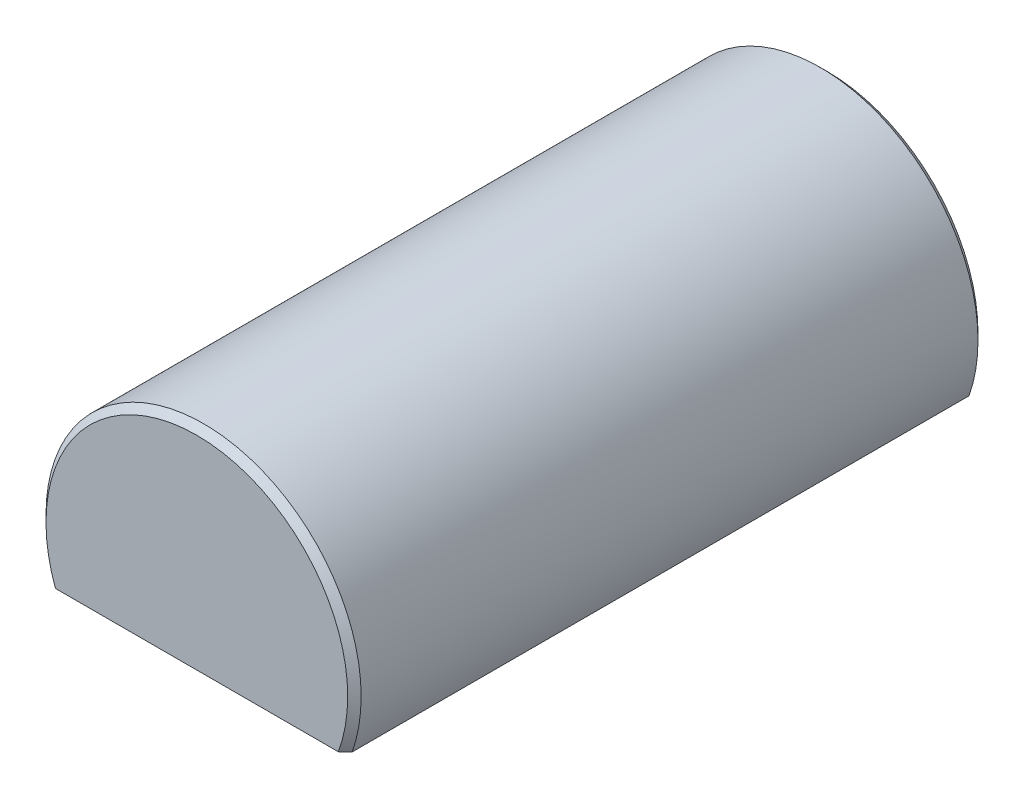
from build123d import *

# Parameters (mm, degrees)
SKETCH1_R            = 9.525
EXTRUDE1_DEPTH       = 19.05
CHAMFER1_SIZE        = 0.4064
TRUNCATED_DEPTH      = 20.05
TRUNCATED_DEPTH_BACK = 20.05
RECESSED_DEPTH       = 0.127
SKETCH4_R            = 2.5527
THREADED_DEPTH       = 6.35
CHAMFER2_SIZE        = 0.6223


with BuildPart() as part:
    # Sketch1 → Extrude1 (new body, symmetric)
    with BuildSketch(Plane.XY):
        Circle(SKETCH1_R)
    extrude(amount=EXTRUDE1_DEPTH, both=True)

    # Chamfer1
    chamfer1_edges = [part.edges().sort_by_distance(p)[0] for p in [
        (-9.525, 0, -19.05),
        (-9.525, 0, 19.05),
    ]]
    chamfer(chamfer1_edges, length=CHAMFER1_SIZE)

    # Sketch2 → Truncated (cut, two sides)
    with BuildSketch(Plane.XY) as truncated_sk:
        with BuildLine():
            Line((-8.980256121, -3.175), (8.980256121, -3.175))
            ThreePointArc((8.980256121, -3.175), (0, -9.525), (-8.980256121, -3.175))
        make_face()
    extrude(amount=TRUNCATED_DEPTH, mode=Mode.SUBTRACT)
    extrude(truncated_sk.sketch, amount=-TRUNCATED_DEPTH_BACK, mode=Mode.SUBTRACT)

    # Sketch3 → Recessed (cut)
    with BuildSketch(Plane.XZ.offset(3.175)):
        with BuildLine():
            Line((6.091006121, 16.66875), (-6.091006121, 16.66875))
            ThreePointArc((-6.091006121, 16.66875), (-6.450216366, 16.519960245), (-6.599006121, 16.16075))
            Line((-6.599006121, 16.16075), (-6.599006121, -16.16075))
            ThreePointArc((-6.599006121, -16.16075), (-6.450216366, -16.519960245), (-6.091006121, -16.66875))
            Line((-6.091006121, -16.66875), (6.091006121, -16.66875))
            ThreePointArc((6.091006121, -16.66875), (6.450216366, -16.519960245), (6.599006121, -16.16075))
            Line((6.599006121, -16.16075), (6.599006121, 16.16075))
            ThreePointArc((6.599006121, 16.16075), (6.450216366, 16.519960245), (6.091006121, 16.66875))
        make_face()
    extrude(amount=-RECESSED_DEPTH, mode=Mode.SUBTRACT)

    # Sketch4 → Threaded (cut)
    with BuildSketch(Plane.XZ.offset(3.175)):
        with Locations(Location((0, 12.7, 0), (0, 0, 270))):  # turned: the seam where the file's is
            Circle(SKETCH4_R)
        with Locations(Location((0, -12.7, 0), (0, 0, 270))):  # turned: the seam where the file's is
            Circle(SKETCH4_R)
    extrude(amount=-THREADED_DEPTH, mode=Mode.SUBTRACT)

    # Chamfer2
    chamfer2_edges = [part.edges().sort_by_distance(p)[0] for p in [
        (0, -3.048, 15.2527),
        (0, -3.048, -10.1473),
    ]]
    chamfer(chamfer2_edges, length=CHAMFER2_SIZE)


solid = part.part
